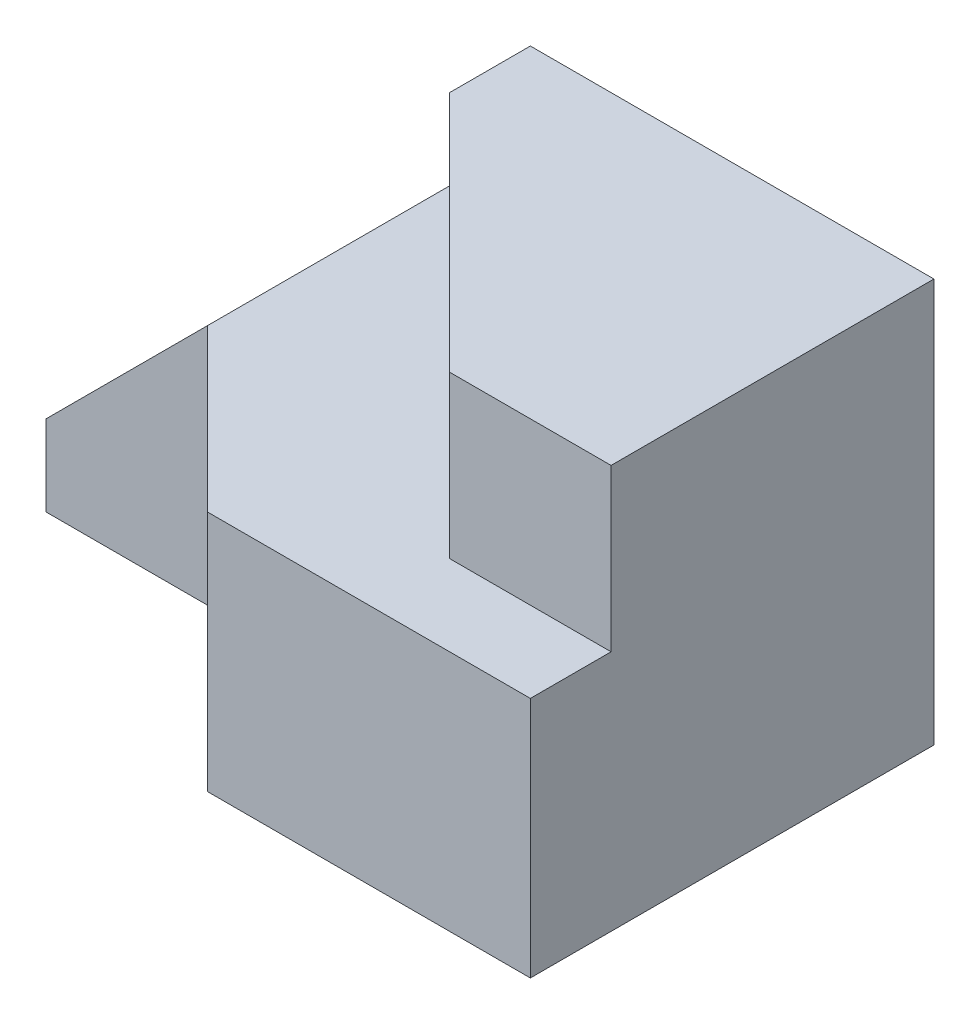
from build123d import *

# Parameters (mm, degrees)
SKETCH1_W           = 60
SKETCH1_H           = 50
BOSS_EXTRUDE1_DEPTH = 30
CUT_EXTRUDE1_DEPTH  = 30
BOSS_EXTRUDE2_DEPTH = 20
BOSS_EXTRUDE3_DEPTH = 30


with BuildPart() as part:
    # Sketch1 → Boss-Extrude1 (new body)
    with BuildSketch(Plane(origin=(0, 0, 0), x_dir=(1, 0, 0), z_dir=(0, 1, 0))):
        with Locations((30, 25)):
            Rectangle(SKETCH1_W, SKETCH1_H)
    extrude(amount=BOSS_EXTRUDE1_DEPTH)

    # Sketch2 → Cut-Extrude1 (cut)
    with BuildSketch(Plane(origin=(0, 30, 0), x_dir=(1, 0, 0), z_dir=(0, 1, 0))):
        Polygon((0, 20), (20, 0), (0, 0), align=None)
    extrude(amount=-CUT_EXTRUDE1_DEPTH, mode=Mode.SUBTRACT)

    # Sketch3 → Boss-Extrude2 (add)
    with BuildSketch(Plane(origin=(0, 30, 0), x_dir=(1, 0, 0), z_dir=(0, 1, 0))):
        Polygon((10, 50), (60, 50), (60, 10), (40, 10), (10, 40), align=None)
    extrude(amount=BOSS_EXTRUDE2_DEPTH)

    # Sketch4 → Boss-Extrude3 (add)
    with BuildSketch(Plane(origin=(0, 0, -50), x_dir=(-1, 0, 0), z_dir=(0, 0, -1))):
        Polygon((20, 0), (20, 10), (0, 30), (0, 0), align=None)
    extrude(amount=-BOSS_EXTRUDE3_DEPTH)


solid = part.part
